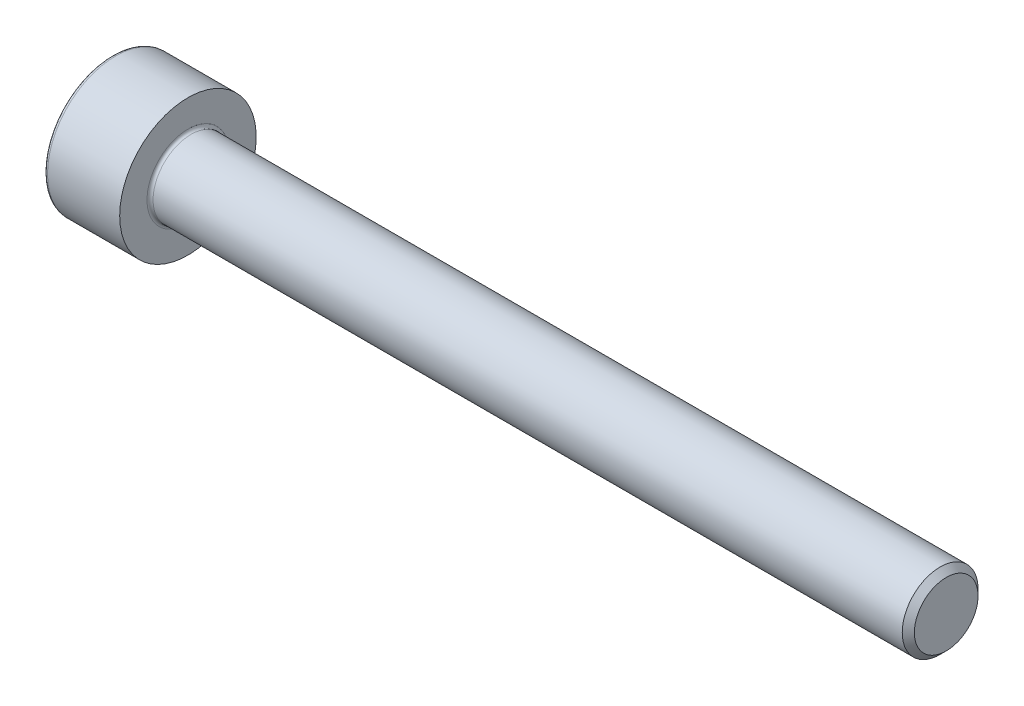
from build123d import *

# Parameters (mm, degrees)
FILLET1_R      = 0.1
FILLET2_R      = 0.12
CHAMFER1_SIZE  = 0.2
EXTRUDE1_DEPTH = 1.1


with BuildPart() as part:
    # Sketch1 → Revolve1 (revolve)
    with BuildSketch(Plane.XY, mode=Mode.PRIVATE) as revolve1_sk:
        Polygon((2.5, 1.25), (2.5, 0), (4.279914881, 0), (27.5, 0), (27.5, 1.25), align=None)
        Polygon((0, 2.25), (0, 0), (2.5, 0), (2.5, 1.25), (2.5, 2.25), align=None)
    revolve(revolve1_sk.sketch.rotate(Axis((0, 0, 0), (1, 0, 0)), 90), axis=Axis((0, 0, 0), (1, 0, 0)))

    # Fillet1
    fillet1_edges = [part.edges().sort_by_distance(p)[0] for p in [
        (2.5, 0, -1.25),
    ]]
    fillet(fillet1_edges, radius=FILLET1_R)

    # Fillet2
    fillet2_edges = [part.edges().sort_by_distance(p)[0] for p in [
        (0, 0, -2.25),
    ]]
    fillet(fillet2_edges, radius=FILLET2_R)

    # Chamfer1
    chamfer1_edges = [part.edges().sort_by_distance(p)[0] for p in [
        (27.5, 0, -1.25),
    ]]
    chamfer(chamfer1_edges, length=CHAMFER1_SIZE)

    # Sketch2 → Extrude1 (cut)
    with BuildSketch(Plane.ZY):
        Polygon((0, 1.154700538), (-1, 0.577350269), (-1, -0.577350269), (0, -1.154700538), (1, -0.577350269), (1, 0.577350269), align=None)
    extrude(amount=-EXTRUDE1_DEPTH, mode=Mode.SUBTRACT)


solid = part.part
